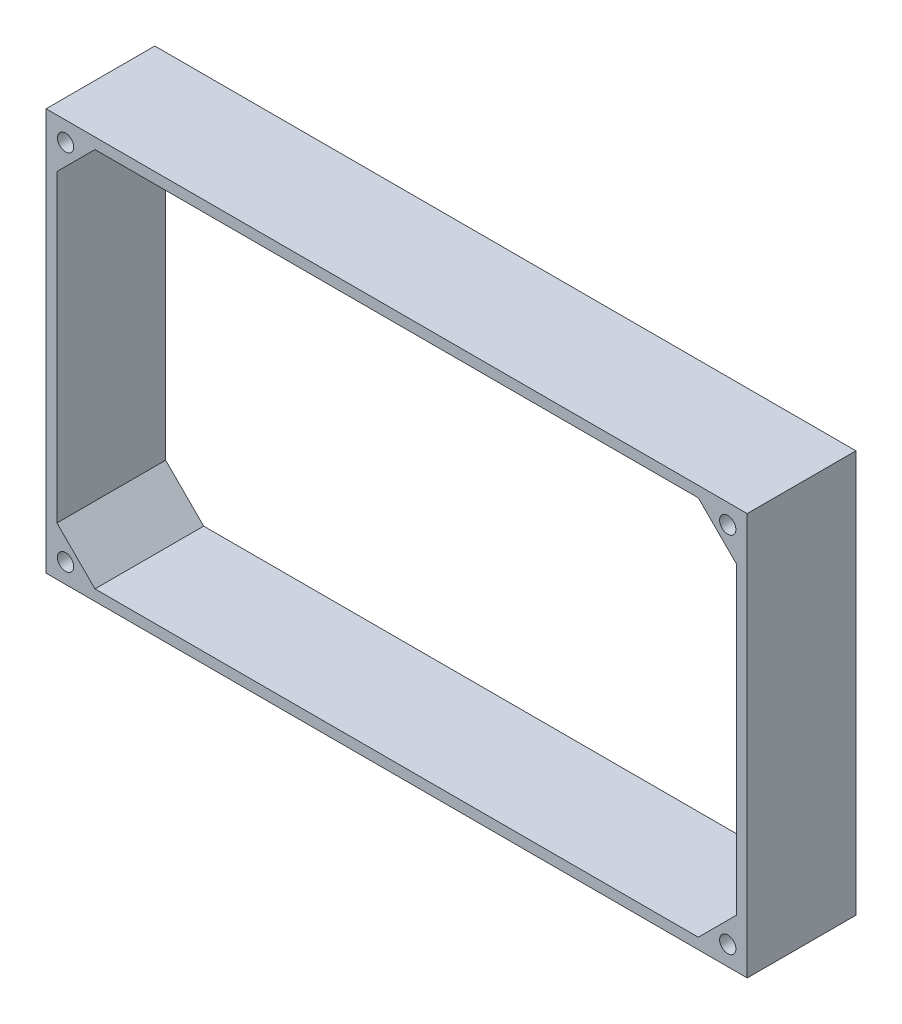
from build123d import *

# Parameters (mm, degrees)
ESQUISSE1_W        = 258
ESQUISSE1_H        = 148
ESQUISSE1_R        = 3
BOSS_EXTRU_2_DEPTH = 40


with BuildPart() as part:
    # Esquisse1 → Boss.-Extru.2 (new body)
    with BuildSketch(Plane.XY):
        Rectangle(ESQUISSE1_W, ESQUISSE1_H)
        with Locations((-121.832077187, -66.832077187)):
            Circle(ESQUISSE1_R, mode=Mode.SUBTRACT)
        with Locations((-121.832077187, 66.832077187)):
            Circle(ESQUISSE1_R, mode=Mode.SUBTRACT)
        with Locations((121.832077187, -66.832077187)):
            Circle(ESQUISSE1_R, mode=Mode.SUBTRACT)
        with Locations((121.832077187, 66.832077187)):
            Circle(ESQUISSE1_R, mode=Mode.SUBTRACT)
        Polygon((-111, -70), (111, -70), (125, -56), (125, 56), (111, 70), (-111, 70), (-125, 56), (-125, -56), align=None, mode=Mode.SUBTRACT)
    extrude(amount=BOSS_EXTRU_2_DEPTH)


solid = part.part
